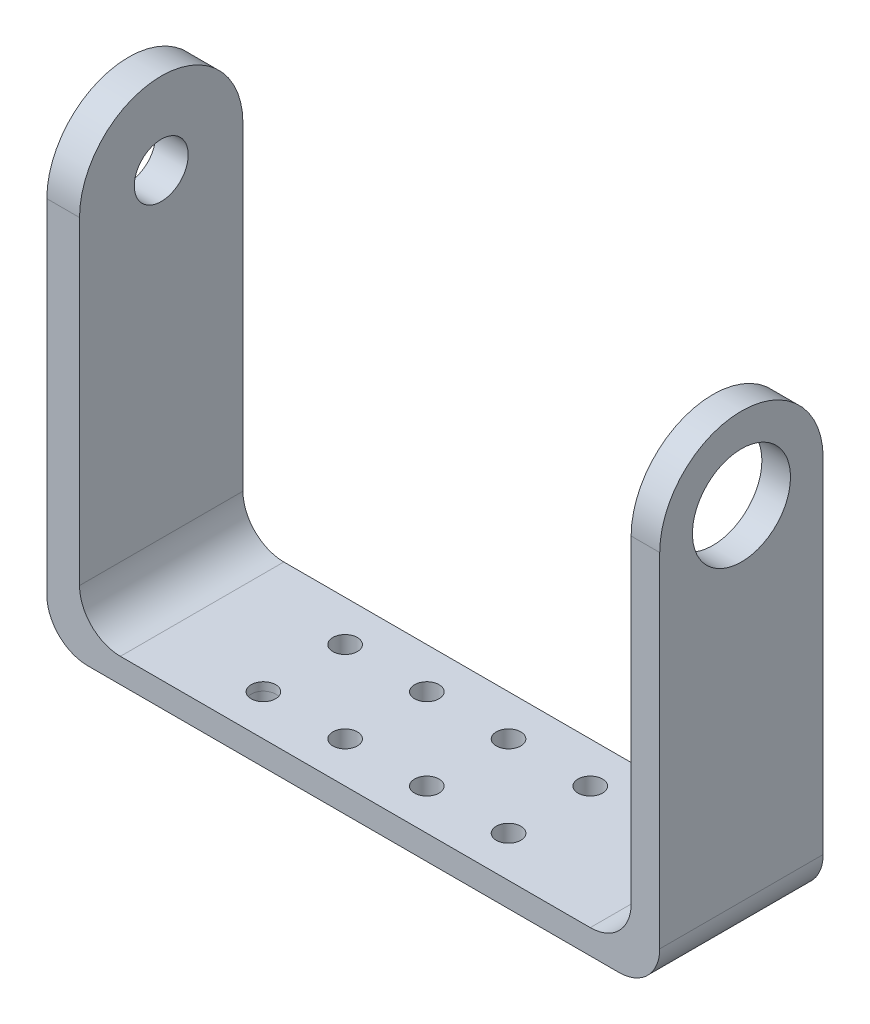
from build123d import *

# Parameters (mm, degrees)
SKETCH_2_R          = 1.5
EXTRUDE_1_DEPTH     = 2
SKETCH_3_W          = 2.5
SKETCH_3_H          = 20
SKETCH_3_W_2        = 3.5
EXTRUDE_2_DEPTH     = 55
SKETCH_9_R          = 6
CUT_EXTRUDE_1_DEPTH = 87
SKETCH_7_R          = 6
SKETCH_7_R_2        = 3.3
EXTRUDE_3_DEPTH     = 2.5
SKETCH_10_R         = 3.3
EXTRUDE_4_DEPTH     = 1.5
SKETCH_11_W         = 67.5
SKETCH_11_H         = 20
SKETCH_11_R         = 1.5
SKETCH_11_R_2       = 1.498871695
EXTRUDE_5_DEPTH     = 1
FILLET_6_R          = 5
FILLET_7_R          = 5
FILLET_8_R          = 5


with BuildPart() as part:
    # 스케치2 → 보스-돌출1 (new body)
    with BuildSketch(Plane(origin=(0, 0, 0), x_dir=(1, 0, 0), z_dir=(0, 1, 0))):
        Polygon((35, -10), (-35, -10), (-35, 10), (35, 10), (38.5, 10), (38.5, -10), align=None)
        with Locations((-15, 5)):
            Circle(SKETCH_2_R, mode=Mode.SUBTRACT)
        with Locations((-5, 5)):
            Circle(SKETCH_2_R, mode=Mode.SUBTRACT)
        with Locations((-15, -5)):
            Circle(SKETCH_2_R, mode=Mode.SUBTRACT)
        with Locations((-5, -5)):
            Circle(SKETCH_2_R, mode=Mode.SUBTRACT)
        with Locations((15, -5)):
            Circle(SKETCH_2_R, mode=Mode.SUBTRACT)
        with Locations((5, -5)):
            Circle(SKETCH_2_R, mode=Mode.SUBTRACT)
        with Locations((5, 5)):
            Circle(SKETCH_2_R, mode=Mode.SUBTRACT)
        with Locations((15, 5)):
            Circle(SKETCH_2_R, mode=Mode.SUBTRACT)
    extrude(amount=EXTRUDE_1_DEPTH)

    # 스케치3 → 보스-돌출2 (add)
    with BuildSketch(Plane(origin=(0, 2, 0), x_dir=(1, 0, 0), z_dir=(0, 1, 0))):
        with Locations((-33.75, 0)):
            Rectangle(SKETCH_3_W, SKETCH_3_H)
        with Locations((36.75, 0)):
            Rectangle(SKETCH_3_W_2, SKETCH_3_H)
    extrude(amount=EXTRUDE_2_DEPTH)

    # 스케치9 → 컷-돌출1 (cut)
    with BuildSketch(Plane(origin=(38.5, 0, 0), x_dir=(0, 0, -1), z_dir=(1, 0, 0))):
        with BuildLine():
            Line((10, 57), (0, 57))
            ThreePointArc((0, 57), (7.071067812, 54.071067812), (10, 47))
            Line((10, 47), (10, 57))
        make_face()
        with BuildLine():
            Line((-10, 57), (-10, 47))
            ThreePointArc((-10, 47), (-7.071067812, 54.071067812), (0, 57))
            Line((0, 57), (-10, 57))
        make_face()
        with Locations((0, 47)):
            Circle(SKETCH_9_R)
    extrude(amount=-CUT_EXTRUDE_1_DEPTH, mode=Mode.SUBTRACT)

    # 스케치7 → 보스-돌출3 (add)
    with BuildSketch(Plane.ZY.offset(35)):
        with Locations((0, 47)):
            Circle(SKETCH_7_R)
        with Locations((0, 47)):
            Circle(SKETCH_7_R_2, mode=Mode.SUBTRACT)
    extrude(amount=-EXTRUDE_3_DEPTH)

    # 스케치10 → 보스-돌출4 (add)
    with BuildSketch(Plane.ZY.offset(35)):
        with BuildLine():
            ThreePointArc((-10, 47), (0, 57), (10, 47))
            Line((10, 47), (10, 0))
            Line((10, 0), (-10, 0))
            Line((-10, 0), (-10, 47))
        make_face()
        with Locations((0, 47)):
            Circle(SKETCH_10_R, mode=Mode.SUBTRACT)
    extrude(amount=EXTRUDE_4_DEPTH)

    # 스케치11 → 보스-돌출5 (add)
    with BuildSketch(Plane(origin=(0, 2, 0), x_dir=(1, 0, 0), z_dir=(0, 1, 0))):
        with Locations((1.25, 0)):
            Rectangle(SKETCH_11_W, SKETCH_11_H)
        with Locations((-15, 5)):
            Circle(SKETCH_11_R, mode=Mode.SUBTRACT)
        with Locations((-5, 5)):
            Circle(SKETCH_11_R, mode=Mode.SUBTRACT)
        with Locations((5, 5)):
            Circle(SKETCH_11_R, mode=Mode.SUBTRACT)
        with Locations((15, 5)):
            Circle(SKETCH_11_R, mode=Mode.SUBTRACT)
        with Locations((15, -5)):
            Circle(SKETCH_11_R, mode=Mode.SUBTRACT)
        with Locations((5, -5)):
            Circle(SKETCH_11_R, mode=Mode.SUBTRACT)
        with Locations((-5, -5)):
            Circle(SKETCH_11_R, mode=Mode.SUBTRACT)
        with Locations((-15, -5)):
            Circle(SKETCH_11_R_2, mode=Mode.SUBTRACT)
    extrude(amount=EXTRUDE_5_DEPTH)

    # 필렛6
    fillet_6_edges = [part.edges().sort_by_distance(p)[0] for p in [
        (-32.5, 3, 0),
    ]]
    fillet(fillet_6_edges, radius=FILLET_6_R)

    # 필렛7
    fillet_7_edges = [part.edges().sort_by_distance(p)[0] for p in [
        (35, 3, 0),
    ]]
    fillet(fillet_7_edges, radius=FILLET_7_R)

    # 필렛8
    fillet_8_edges = [part.edges().sort_by_distance(p)[0] for p in [
        (-36.5, 0, 0),
        (38.5, 0, 0),
    ]]
    fillet(fillet_8_edges, radius=FILLET_8_R)


solid = part.part
